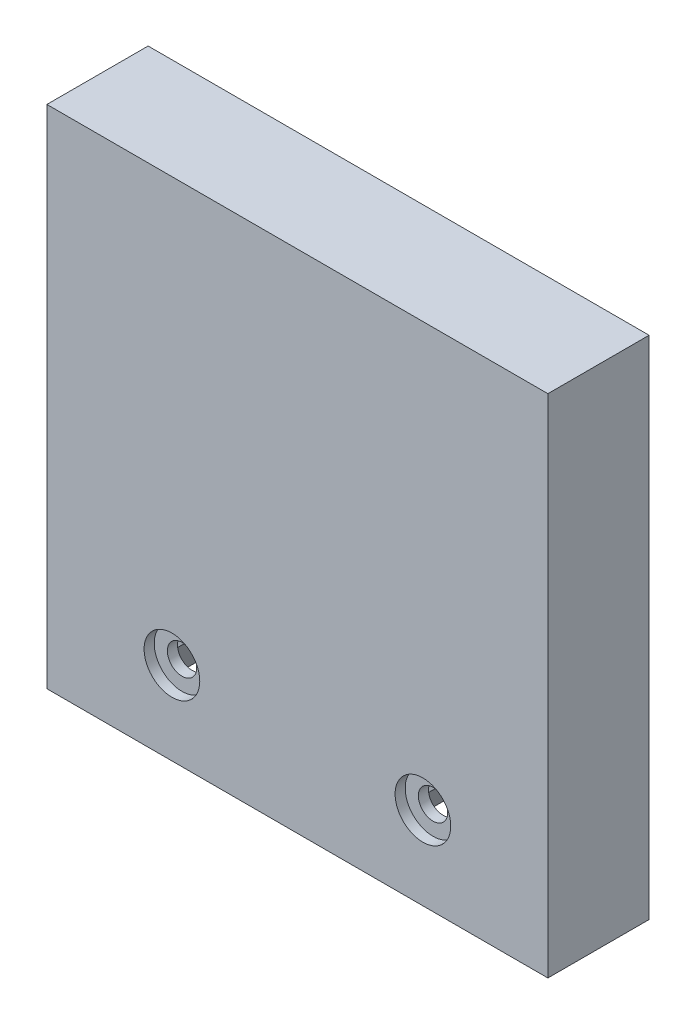
from build123d import *

# Parameters (mm, degrees)
SKETCH1_W           = 49.5
SKETCH1_H           = 50.000619057
BOSS_EXTRUDE1_DEPTH = 10
CUT_EXTRUDE1_DEPTH  = 8
SKETCH4_R           = 1.45
CUT_EXTRUDE2_DEPTH  = 8
SKETCH5_R           = 2.75
CUT_EXTRUDE3_DEPTH  = 1
SKETCH6_R           = 5
CUT_EXTRUDE4_DEPTH  = 3


with BuildPart() as part:
    # Sketch1 → Boss-Extrude1 (new body)
    with BuildSketch(Plane.XY):
        with Locations((1.875288206, 25.000309529)):
            Rectangle(SKETCH1_W, SKETCH1_H)
    extrude(amount=BOSS_EXTRUDE1_DEPTH)

    # Sketch3 → Cut-Extrude1 (cut)
    with BuildSketch(Plane(origin=(0, 0, 0), x_dir=(-1, 0, 0), z_dir=(0, 0, -1))):
        with BuildLine():
            Line((17.871256182, -0.2), (14.760723675, 5.183428821))
            ThreePointArc((14.760723675, 5.183428821), (10.522339102, 13.396152422), (6.2841063, 5.183350498))
            Line((6.2841063, 5.183350498), (4.25724424, 1.67))
            Line((4.25724424, 1.67), (-8.010847692, 1.67))
            Line((-8.010847692, 1.67), (-10.03930416, 5.183389663))
            ThreePointArc((-10.03930416, 5.183389663), (-14.277636876, 13.396152423), (-18.5158937, 5.183350498))
            Line((-18.5158937, 5.183350498), (-21.621564167, -0.2))
            Line((-21.621564167, -0.2), (17.871256182, -0.2))
        make_face()
    extrude(amount=-CUT_EXTRUDE1_DEPTH, mode=Mode.SUBTRACT)

    # Sketch4 → Cut-Extrude2 (cut)
    with BuildSketch(Plane(origin=(0, 0, 8), x_dir=(-1, 0, 0), z_dir=(0, 0, -1))):
        with Locations((-14.27761285, 8.196152423)):
            Circle(SKETCH4_R)
        with Locations((10.52238715, 8.196152423)):
            Circle(SKETCH4_R)
    extrude(amount=-CUT_EXTRUDE2_DEPTH, mode=Mode.SUBTRACT)

    # Sketch5 → Cut-Extrude3 (cut)
    with BuildSketch(Plane.XY.offset(10)):
        with Locations((-10.52238715, 8.196152423)):
            Circle(SKETCH5_R)
        with Locations((14.27761285, 8.196152423)):
            Circle(SKETCH5_R)
    extrude(amount=-CUT_EXTRUDE3_DEPTH, mode=Mode.SUBTRACT)

    # Sketch6 → Cut-Extrude4 (cut)
    with BuildSketch(Plane(origin=(0, 0, 0), x_dir=(-1, 0, 0), z_dir=(0, 0, -1))):
        with Locations((-1.875273442, 33.500619057)):
            Circle(SKETCH6_R)
    extrude(amount=-CUT_EXTRUDE4_DEPTH, mode=Mode.SUBTRACT)


solid = part.part
